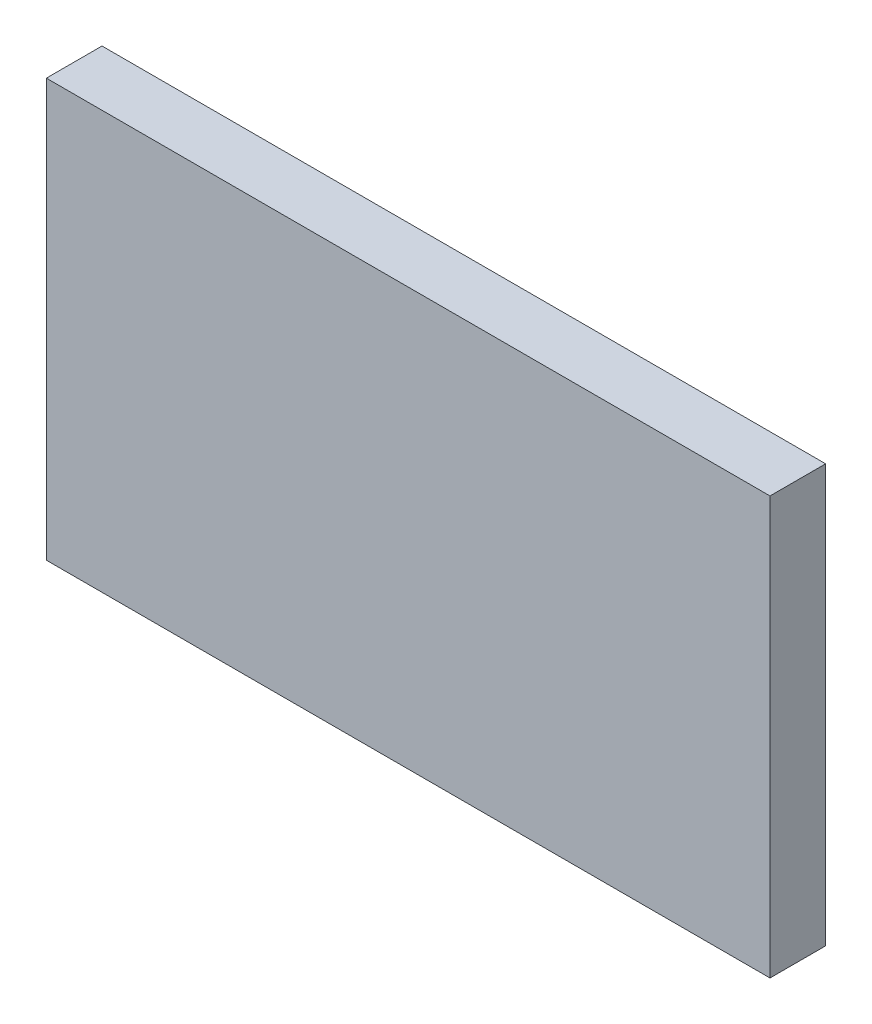
from build123d import *

# Parameters (mm, degrees)
SKETCH1_W           = 130
SKETCH1_H           = 10
BOSS_EXTRUDE1_DEPTH = 75


with BuildPart() as part:
    # Sketch1 → Boss-Extrude1 (new body)
    with BuildSketch(Plane(origin=(0, 0, 0), x_dir=(1, 0, 0), z_dir=(0, 1, 0))):
        with Locations((-65, 5)):
            Rectangle(SKETCH1_W, SKETCH1_H)
    extrude(amount=BOSS_EXTRUDE1_DEPTH)


solid = part.part
